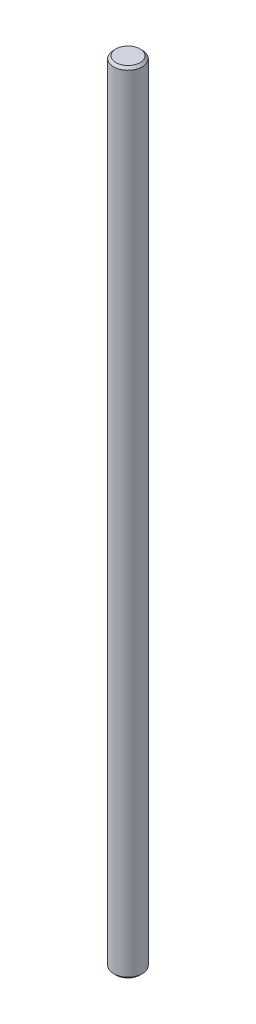
from build123d import *

# Parameters (mm, degrees)
SKETCH1_R      = 6
EXTRUDE1_DEPTH = 330
CHAMFER1_SIZE  = 1


with BuildPart() as part:
    # Sketch1 → Extrude1 (new body)
    with BuildSketch(Plane(origin=(0, 0, 0), x_dir=(1, 0, 0), z_dir=(0, 1, 0))):
        with Locations((0, 0.010418865)):
            Circle(SKETCH1_R)
    extrude(amount=EXTRUDE1_DEPTH)

    # Chamfer1
    chamfer1_edges = [part.edges().sort_by_distance(p)[0] for p in [
        (-6, 0, -0.010418865),
        (-6, 330, -0.010418865),
    ]]
    chamfer(chamfer1_edges, length=CHAMFER1_SIZE)


solid = part.part
